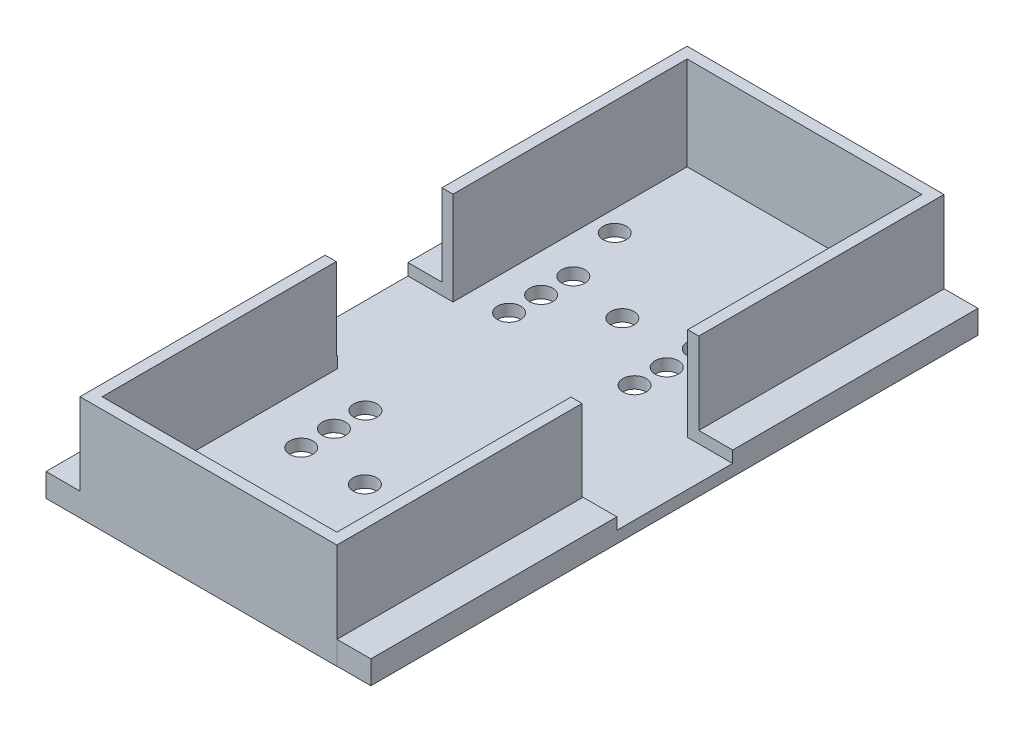
from build123d import *

# Parameters (mm, degrees)
SKETCH1_W               = 22
SKETCH1_H               = 52
BOSS_EXTRUDE1_DEPTH     = 9
CUT_EXTRUDE1_START      = 2
SKETCH2_W               = 20.1
SKETCH2_H               = 50.1
CUT_EXTRUDE1_DEPTH      = 10
CUT_EXTRUDE6_DEPTH      = 30.342801502
CUT_EXTRUDE6_DEPTH_BACK = 30.342801502
SKETCH7_R               = 0.8
CUT_EXTRUDE7_REACH      = 31.343
SKETCH8_R               = 1
CUT_EXTRUDE9_REACH      = 31.343
SKETCH9_R               = 1
CUT_EXTRUDE10_REACH     = 31.343
SKETCH10_R              = 1
CUT_EXTRUDE11_REACH     = 31.343
SKETCH11_R              = 1
CUT_EXTRUDE12_REACH     = 31.343
SKETCH12_R              = 1
CUT_EXTRUDE13_REACH     = 31.343
SKETCH13_R              = 1
CUT_EXTRUDE14_REACH     = 31.343
SKETCH14_R              = 1
CUT_EXTRUDE15_REACH     = 31.343
SKETCH15_R              = 1
CUT_EXTRUDE16_REACH     = 31.343
SKETCH16_R              = 1
SKETCH18_W              = 2.91
SKETCH18_H              = 52
BOSS_EXTRUDE2_DEPTH     = 2
SKETCH18_3_W            = 2.9
SKETCH18_3_H            = 52
BOSS_EXTRUDE3_DEPTH     = 2
SKETCH19_W              = 10
SKETCH19_H              = 7
CUT_EXTRUDE17_DEPTH     = 38.117183598
SKETCH20_W              = 3.86
SKETCH20_H              = 9.915252407
SKETCH20_W_2            = 4.307713093
CUT_EXTRUDE18_DEPTH     = 1


with BuildPart() as part:
    # Sketch1 → Boss-Extrude1 (new body)
    with BuildSketch(Plane(origin=(0, 0, 0), x_dir=(1, 0, 0), z_dir=(0, 1, 0))):
        Rectangle(SKETCH1_W, SKETCH1_H)
    extrude(amount=BOSS_EXTRUDE1_DEPTH)

    # Sketch2 → Cut-Extrude1 (cut)
    with BuildSketch(Plane(origin=(0, 9, 0), x_dir=(1, 0, 0), z_dir=(0, 1, 0)).offset(CUT_EXTRUDE1_START)):
        Rectangle(SKETCH2_W, SKETCH2_H)
    extrude(amount=-CUT_EXTRUDE1_DEPTH, mode=Mode.SUBTRACT)

    # Sketch7 → Cut-Extrude6 (cut, two sides: drawn at the far end of the back side and taken through both)
    with BuildSketch(Plane(origin=(0, 1, 0), x_dir=(1, 0, 0), z_dir=(0, 1, 0)).offset(-CUT_EXTRUDE6_DEPTH_BACK)):
        with Locations((-8.15, -23)):
            Circle(SKETCH7_R)
    extrude(amount=CUT_EXTRUDE6_DEPTH + CUT_EXTRUDE6_DEPTH_BACK, mode=Mode.SUBTRACT)

    # Sketch8 → Cut-Extrude7 (cut, up to next)
    with BuildSketch(Plane(origin=(0, 1, 0), x_dir=(1, 0, 0), z_dir=(0, 1, 0)), mode=Mode.PRIVATE) as cut_extrude7_sk1:
        with Locations((-5.75, -12.3)):
            Circle(SKETCH8_R)
    cut_extrude7_tool1 = extrude(cut_extrude7_sk1.sketch, amount=-CUT_EXTRUDE7_REACH, mode=Mode.PRIVATE) & part.part
    # Sketch8 → Cut-Extrude7 (cut, up to next)
    with BuildSketch(Plane(origin=(0, 1, 0), x_dir=(1, 0, 0), z_dir=(0, 1, 0)), mode=Mode.PRIVATE) as cut_extrude7_sk2:
        with Locations((5, -12.3)):
            Circle(SKETCH8_R)
    cut_extrude7_tool2 = extrude(cut_extrude7_sk2.sketch, amount=-CUT_EXTRUDE7_REACH, mode=Mode.PRIVATE) & part.part
    add(cut_extrude7_tool1.solids().sort_by_distance((-5.75, 1, 12.3))[0], mode=Mode.SUBTRACT)
    add(cut_extrude7_tool2.solids().sort_by_distance((5, 1, 12.3))[0], mode=Mode.SUBTRACT)

    # Sketch9 → Cut-Extrude9 (cut, up to next)
    with BuildSketch(Plane(origin=(0, 1, 0), x_dir=(1, 0, 0), z_dir=(0, 1, 0)), mode=Mode.PRIVATE) as cut_extrude9_sk1:
        with Locations((-5.75, -9.5)):
            Circle(SKETCH9_R)
    cut_extrude9_tool1 = extrude(cut_extrude9_sk1.sketch, amount=-CUT_EXTRUDE9_REACH, mode=Mode.PRIVATE) & part.part
    # Sketch9 → Cut-Extrude9 (cut, up to next)
    with BuildSketch(Plane(origin=(0, 1, 0), x_dir=(1, 0, 0), z_dir=(0, 1, 0)), mode=Mode.PRIVATE) as cut_extrude9_sk2:
        with Locations((5, -9.5)):
            Circle(SKETCH9_R)
    cut_extrude9_tool2 = extrude(cut_extrude9_sk2.sketch, amount=-CUT_EXTRUDE9_REACH, mode=Mode.PRIVATE) & part.part
    add(cut_extrude9_tool1.solids().sort_by_distance((-5.75, 1, 9.5))[0], mode=Mode.SUBTRACT)
    add(cut_extrude9_tool2.solids().sort_by_distance((5, 1, 9.5))[0], mode=Mode.SUBTRACT)

    # Sketch10 → Cut-Extrude10 (cut, up to next)
    with BuildSketch(Plane(origin=(0, 1, 0), x_dir=(1, 0, 0), z_dir=(0, 1, 0)), mode=Mode.PRIVATE) as cut_extrude10_sk1:
        with Locations((-5.75, -6.8)):
            Circle(SKETCH10_R)
    cut_extrude10_tool1 = extrude(cut_extrude10_sk1.sketch, amount=-CUT_EXTRUDE10_REACH, mode=Mode.PRIVATE) & part.part
    # Sketch10 → Cut-Extrude10 (cut, up to next)
    with BuildSketch(Plane(origin=(0, 1, 0), x_dir=(1, 0, 0), z_dir=(0, 1, 0)), mode=Mode.PRIVATE) as cut_extrude10_sk2:
        with Locations((5, -6.837159935)):
            Circle(SKETCH10_R)
    cut_extrude10_tool2 = extrude(cut_extrude10_sk2.sketch, amount=-CUT_EXTRUDE10_REACH, mode=Mode.PRIVATE) & part.part
    add(cut_extrude10_tool1.solids().sort_by_distance((-5.75, 1, 6.8))[0], mode=Mode.SUBTRACT)
    add(cut_extrude10_tool2.solids().sort_by_distance((5, 1, 6.83716))[0], mode=Mode.SUBTRACT)

    # Sketch11 → Cut-Extrude11 (cut, up to next)
    with BuildSketch(Plane(origin=(0, 1, 0), x_dir=(1, 0, 0), z_dir=(0, 1, 0)), mode=Mode.PRIVATE) as cut_extrude11_sk1:
        with Locations((-0.3, -12.3)):
            Circle(SKETCH11_R)
    cut_extrude11_tool1 = extrude(cut_extrude11_sk1.sketch, amount=-CUT_EXTRUDE11_REACH, mode=Mode.PRIVATE) & part.part
    add(cut_extrude11_tool1.solids().sort_by_distance((-0.3, 1, 12.3))[0], mode=Mode.SUBTRACT)

    # Sketch12 → Cut-Extrude12 (cut, up to next)
    with BuildSketch(Plane(origin=(0, 1, 0), x_dir=(1, 0, 0), z_dir=(0, 1, 0)), mode=Mode.PRIVATE) as cut_extrude12_sk1:
        with Locations((3.95, 12.05)):
            Circle(SKETCH12_R)
    cut_extrude12_tool1 = extrude(cut_extrude12_sk1.sketch, amount=-CUT_EXTRUDE12_REACH, mode=Mode.PRIVATE) & part.part
    # Sketch12 → Cut-Extrude12 (cut, up to next)
    with BuildSketch(Plane(origin=(0, 1, 0), x_dir=(1, 0, 0), z_dir=(0, 1, 0)), mode=Mode.PRIVATE) as cut_extrude12_sk2:
        with Locations((-6.8, 12.05)):
            Circle(SKETCH12_R)
    cut_extrude12_tool2 = extrude(cut_extrude12_sk2.sketch, amount=-CUT_EXTRUDE12_REACH, mode=Mode.PRIVATE) & part.part
    add(cut_extrude12_tool1.solids().sort_by_distance((3.95, 1, -12.05))[0], mode=Mode.SUBTRACT)
    add(cut_extrude12_tool2.solids().sort_by_distance((-6.8, 1, -12.05))[0], mode=Mode.SUBTRACT)

    # Sketch13 → Cut-Extrude13 (cut, up to next)
    with BuildSketch(Plane(origin=(0, 1, 0), x_dir=(1, 0, 0), z_dir=(0, 1, 0)), mode=Mode.PRIVATE) as cut_extrude13_sk1:
        with Locations((3.95, 9.3)):
            Circle(SKETCH13_R)
    cut_extrude13_tool1 = extrude(cut_extrude13_sk1.sketch, amount=-CUT_EXTRUDE13_REACH, mode=Mode.PRIVATE) & part.part
    # Sketch13 → Cut-Extrude13 (cut, up to next)
    with BuildSketch(Plane(origin=(0, 1, 0), x_dir=(1, 0, 0), z_dir=(0, 1, 0)), mode=Mode.PRIVATE) as cut_extrude13_sk2:
        with Locations((-6.8, 9.3)):
            Circle(SKETCH13_R)
    cut_extrude13_tool2 = extrude(cut_extrude13_sk2.sketch, amount=-CUT_EXTRUDE13_REACH, mode=Mode.PRIVATE) & part.part
    add(cut_extrude13_tool1.solids().sort_by_distance((3.95, 1, -9.3))[0], mode=Mode.SUBTRACT)
    add(cut_extrude13_tool2.solids().sort_by_distance((-6.8, 1, -9.3))[0], mode=Mode.SUBTRACT)

    # Sketch14 → Cut-Extrude14 (cut, up to next)
    with BuildSketch(Plane(origin=(0, 1, 0), x_dir=(1, 0, 0), z_dir=(0, 1, 0)), mode=Mode.PRIVATE) as cut_extrude14_sk1:
        with Locations((3.9, 6.6)):
            Circle(SKETCH14_R)
    cut_extrude14_tool1 = extrude(cut_extrude14_sk1.sketch, amount=-CUT_EXTRUDE14_REACH, mode=Mode.PRIVATE) & part.part
    # Sketch14 → Cut-Extrude14 (cut, up to next)
    with BuildSketch(Plane(origin=(0, 1, 0), x_dir=(1, 0, 0), z_dir=(0, 1, 0)), mode=Mode.PRIVATE) as cut_extrude14_sk2:
        with Locations((-6.85, 6.6)):
            Circle(SKETCH14_R)
    cut_extrude14_tool2 = extrude(cut_extrude14_sk2.sketch, amount=-CUT_EXTRUDE14_REACH, mode=Mode.PRIVATE) & part.part
    add(cut_extrude14_tool1.solids().sort_by_distance((3.9, 1, -6.6))[0], mode=Mode.SUBTRACT)
    add(cut_extrude14_tool2.solids().sort_by_distance((-6.85, 1, -6.6))[0], mode=Mode.SUBTRACT)

    # Sketch15 → Cut-Extrude15 (cut, up to next)
    with BuildSketch(Plane(origin=(0, 1, 0), x_dir=(1, 0, 0), z_dir=(0, 1, 0)), mode=Mode.PRIVATE) as cut_extrude15_sk1:
        with Locations((-1.6, 11.05)):
            Circle(SKETCH15_R)
    cut_extrude15_tool1 = extrude(cut_extrude15_sk1.sketch, amount=-CUT_EXTRUDE15_REACH, mode=Mode.PRIVATE) & part.part
    add(cut_extrude15_tool1.solids().sort_by_distance((-1.6, 1, -11.05))[0], mode=Mode.SUBTRACT)

    # Sketch16 → Cut-Extrude16 (cut, up to next)
    with BuildSketch(Plane(origin=(0, 1, 0), x_dir=(1, 0, 0), z_dir=(0, 1, 0)), mode=Mode.PRIVATE) as cut_extrude16_sk1:
        with Locations((-8.25, 17.05)):
            Circle(SKETCH16_R)
    cut_extrude16_tool1 = extrude(cut_extrude16_sk1.sketch, amount=-CUT_EXTRUDE16_REACH, mode=Mode.PRIVATE) & part.part
    add(cut_extrude16_tool1.solids().sort_by_distance((-8.25, 1, -17.05))[0], mode=Mode.SUBTRACT)

    # Sketch18 → Boss-Extrude2 (add)
    with BuildSketch(Plane.XZ):
        with Locations((-12.455, 0)):
            Rectangle(SKETCH18_W, SKETCH18_H)
    extrude(amount=-BOSS_EXTRUDE2_DEPTH)

    # Sketch18_3 → Boss-Extrude3 (add)
    with BuildSketch(Plane.XZ):
        with Locations((12.45, -0.012983648)):
            Rectangle(SKETCH18_3_W, SKETCH18_3_H)
    extrude(amount=-BOSS_EXTRUDE3_DEPTH)

    # Sketch19 → Cut-Extrude17 (cut, through all)
    with BuildSketch(Plane.ZY.offset(11)):
        with Locations((0, 5.5)):
            Rectangle(SKETCH19_W, SKETCH19_H)
    extrude(amount=-CUT_EXTRUDE17_DEPTH, mode=Mode.SUBTRACT)

    # Sketch20 → Cut-Extrude18 (cut)
    with BuildSketch(Plane(origin=(0, 2, 0), x_dir=(1, 0, 0), z_dir=(0, 1, 0))):
        with Locations((-11.98, 0.042373796)):
            Rectangle(SKETCH20_W, SKETCH20_H)
        with Locations((12.203856547, 0.042373796)):
            Rectangle(SKETCH20_W_2, SKETCH20_H)
    extrude(amount=-CUT_EXTRUDE18_DEPTH, mode=Mode.SUBTRACT)


solid = part.part
